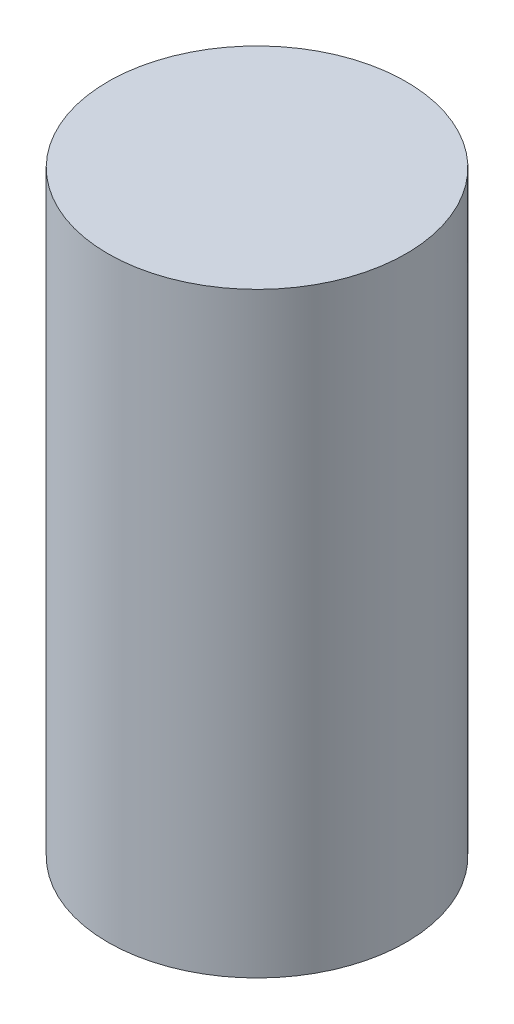
from build123d import *

# Parameters (mm, degrees)
SKETCH2_R           = 20
BOSS_EXTRUDE1_DEPTH = 80


with BuildPart() as part:
    # Sketch2 → Boss-Extrude1 (new body)
    with BuildSketch(Plane(origin=(0, 0, 0), x_dir=(1, 0, 0), z_dir=(0, 1, 0))):
        Circle(SKETCH2_R)
    extrude(amount=BOSS_EXTRUDE1_DEPTH)


solid = part.part
